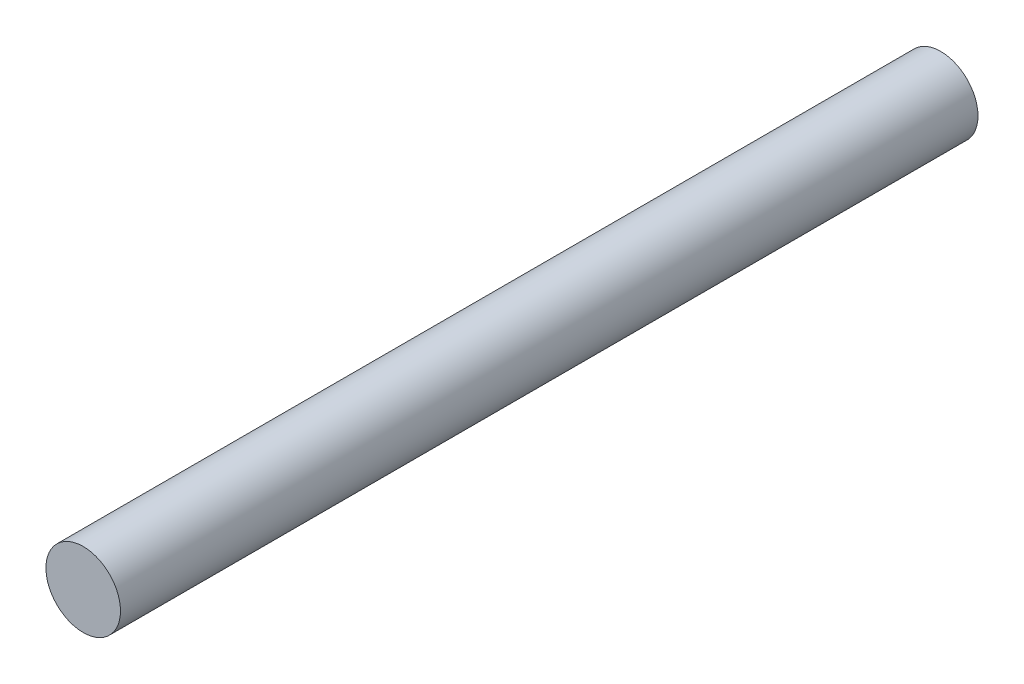
from build123d import *

# Parameters (mm, degrees)
SKETCH1_R           = 1
BOSS_EXTRUDE1_DEPTH = 23


with BuildPart() as part:
    # Sketch1 → Boss-Extrude1 (new body)
    with BuildSketch(Plane.XY):
        Circle(SKETCH1_R)
    extrude(amount=BOSS_EXTRUDE1_DEPTH)


solid = part.part
